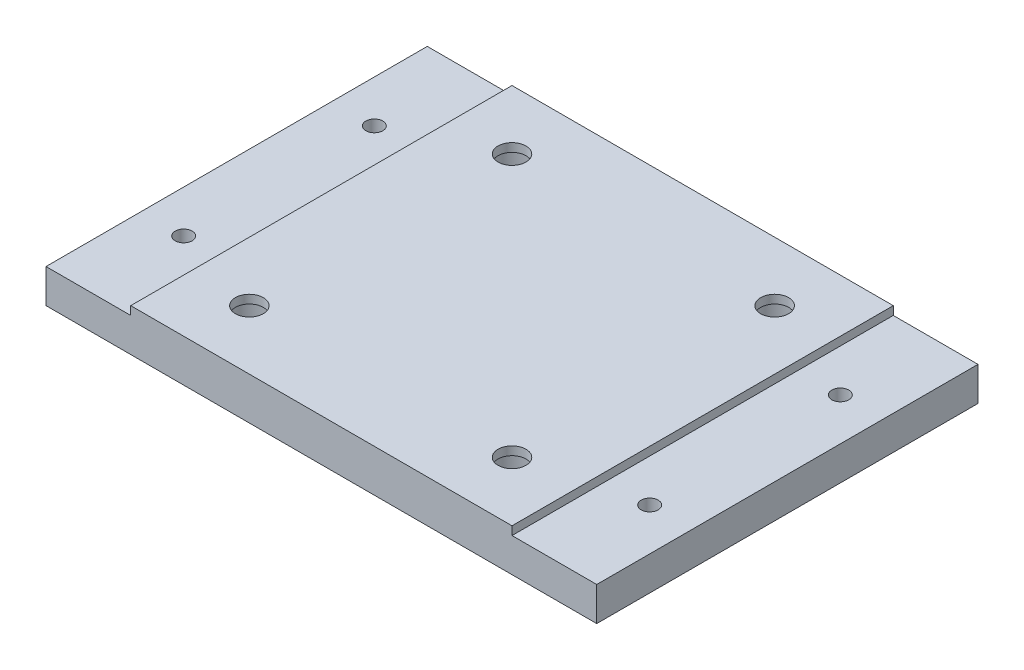
from build123d import *

# Parameters (mm, degrees)
SKETCH1_R           = 3
SKETCH1_R_2         = 1
BOSS_EXTRUDE1_DEPTH = 4
SKETCH2_W           = 45
SKETCH2_H           = 45
SKETCH2_R           = 1.65
BOSS_EXTRUDE2_DEPTH = 1


with BuildPart() as part:
    # Sketch1 → Boss-Extrude1 (new body)
    with BuildSketch(Plane(origin=(0, 0, 0), x_dir=(1, 0, 0), z_dir=(0, 1, 0))):
        Polygon((-22.5, -22.5), (-32.5, -22.5), (-32.5, 22.5), (-22.5, 22.5), (22.5, 22.5), (32.5, 22.5), (32.5, -22.5), (22.5, -22.5), align=None)
        with Locations((-15.5, 15.5)):
            Circle(SKETCH1_R, mode=Mode.SUBTRACT)
        with Locations((15.5, 15.5)):
            Circle(SKETCH1_R, mode=Mode.SUBTRACT)
        with Locations((15.5, -15.5)):
            Circle(SKETCH1_R, mode=Mode.SUBTRACT)
        with Locations((-15.5, -15.5)):
            Circle(SKETCH1_R, mode=Mode.SUBTRACT)
        with Locations((-27.5, 11.25)):
            Circle(SKETCH1_R_2, mode=Mode.SUBTRACT)
        with Locations((-27.5, -11.25)):
            Circle(SKETCH1_R_2, mode=Mode.SUBTRACT)
        with Locations((27.5, 11.25)):
            Circle(SKETCH1_R_2, mode=Mode.SUBTRACT)
        with Locations((27.5, -11.25)):
            Circle(SKETCH1_R_2, mode=Mode.SUBTRACT)
    extrude(amount=BOSS_EXTRUDE1_DEPTH)

    # Sketch2 → Boss-Extrude2 (add)
    with BuildSketch(Plane(origin=(0, 4, 0), x_dir=(1, 0, 0), z_dir=(0, 1, 0))):
        Rectangle(SKETCH2_W, SKETCH2_H)
        with Locations((-15.5, -15.5)):
            Circle(SKETCH2_R, mode=Mode.SUBTRACT)
        with Locations((15.5, -15.5)):
            Circle(SKETCH2_R, mode=Mode.SUBTRACT)
        with Locations((15.5, 15.5)):
            Circle(SKETCH2_R, mode=Mode.SUBTRACT)
        with Locations((-15.5, 15.5)):
            Circle(SKETCH2_R, mode=Mode.SUBTRACT)
    extrude(amount=BOSS_EXTRUDE2_DEPTH)


solid = part.part
